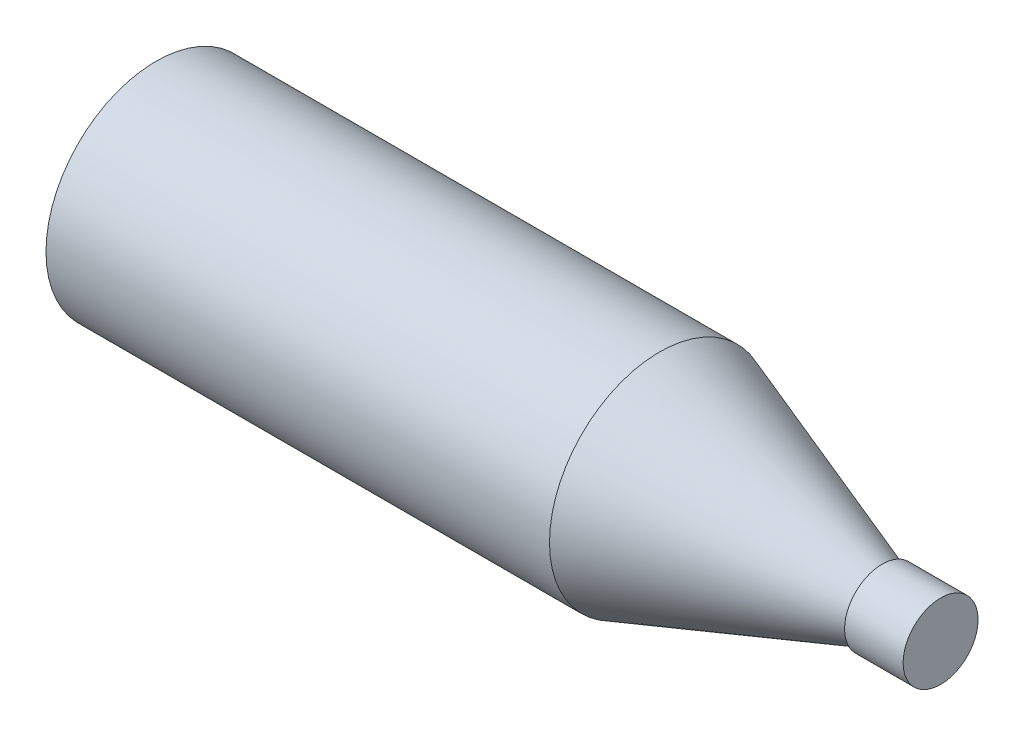
from build123d import *


with BuildPart() as part:
    # Эскиз1 → Повернуть2 (revolve)
    with BuildSketch(Plane.XY, mode=Mode.PRIVATE) as revolve_2_sk:
        Polygon((-50.774937895, 0), (-50.774937895, 47), (164.225062105, 47), (259.225062105, 13.5), (259.225062105, 16), (284.225062105, 16), (284.225062105, 0), align=None)
    revolve(revolve_2_sk.sketch.rotate(Axis((-50.774937895, 0, 0), (1, 0, 0)), 90), axis=Axis((-50.774937895, 0, 0), (1, 0, 0)))  # turned: the seam where the file's is


solid = part.part
